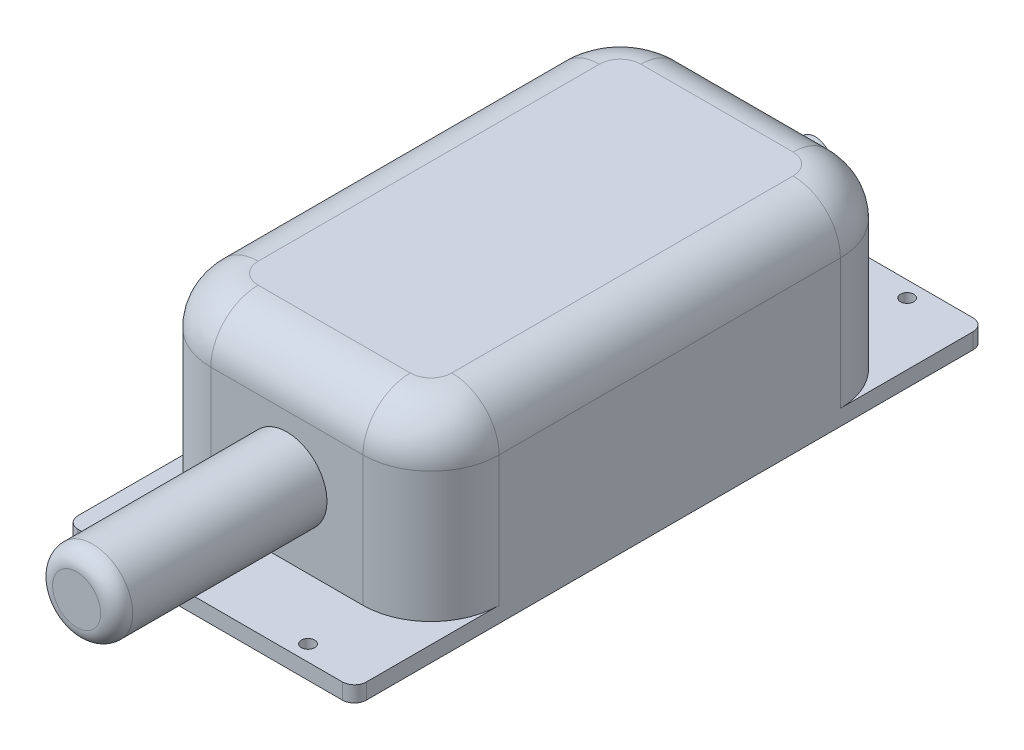
from build123d import *

# Parameters (mm, degrees)
SKETCH1_W           = 91.4146
SKETCH1_H           = 199.9996
BOSS_EXTRUDE1_DEPTH = 5.0038
BOSS_EXTRUDE2_DEPTH = 56.3118
FILLET1_R           = 15.0114
CUT_EXTRUDE1_REACH  = 7.004
SKETCH3_R           = 2.1082
FILLET2_R           = 3.81
SKETCH5_R           = 12.7
BOSS_EXTRUDE3_DEPTH = 66.675
FILLET3_R           = 5.08
SKETCH6_R           = 5.588
BOSS_EXTRUDE4_DEPTH = 16.1544


with BuildPart() as part:
    # Sketch1 → Boss-Extrude1 (new body)
    with BuildSketch(Plane(origin=(0, 0, 0), x_dir=(1, 0, 0), z_dir=(0, 1, 0))):
        Rectangle(SKETCH1_W, SKETCH1_H)
    extrude(amount=BOSS_EXTRUDE1_DEPTH)

    # Sketch2 → Boss-Extrude2 (add)
    with BuildSketch(Plane(origin=(0, 5.0038, 0), x_dir=(1, 0, 0), z_dir=(0, 1, 0))):
        with BuildLine():
            Line((-24.1173, 75.7047), (24.1173, 75.7047))
            ThreePointArc((24.1173, 75.7047), (39.383735406, 69.381135406), (45.7073, 54.1147))
            Line((45.7073, 54.1147), (45.7073, -54.1147))
            ThreePointArc((45.7073, -54.1147), (39.383735406, -69.381135406), (24.1173, -75.7047))
            Line((24.1173, -75.7047), (-24.1173, -75.7047))
            ThreePointArc((-24.1173, -75.7047), (-39.383735406, -69.381135406), (-45.7073, -54.1147))
            Line((-45.7073, -54.1147), (-45.7073, 54.1147))
            ThreePointArc((-45.7073, 54.1147), (-39.383735406, 69.381135406), (-24.1173, 75.7047))
        make_face()
    extrude(amount=BOSS_EXTRUDE2_DEPTH)

    # Fillet1
    fillet1_edges = [part.edges().sort_by_distance(p)[0] for p in [
        (-39.383735406, 61.3156, -69.381135406),
        (-45.7073, 61.3156, 0),
        (-39.383735406, 61.3156, 69.381135406),
        (0, 61.3156, 75.7047),
        (39.383735406, 61.3156, 69.381135406),
        (45.7073, 61.3156, 0),
        (39.383735406, 61.3156, -69.381135406),
        (0, 61.3156, -75.7047),
    ]]
    fillet(fillet1_edges, radius=FILLET1_R)

    # Sketch3 → Cut-Extrude1 (cut, up to next)
    with BuildSketch(Plane(origin=(0, 5.0038, 0), x_dir=(1, 0, 0), z_dir=(0, 1, 0)), mode=Mode.PRIVATE) as cut_extrude1_sk1:
        with Locations((25.9969, 94.996)):
            Circle(SKETCH3_R)
    cut_extrude1_tool1 = extrude(cut_extrude1_sk1.sketch, amount=-CUT_EXTRUDE1_REACH, mode=Mode.PRIVATE) & part.part
    add(cut_extrude1_tool1.solids().sort_by_distance((25.9969, 5.0038, -94.996))[0], mode=Mode.SUBTRACT)
    # Sketch3 → Cut-Extrude1 (cut, up to next)
    with BuildSketch(Plane(origin=(0, 5.0038, 0), x_dir=(1, 0, 0), z_dir=(0, 1, 0)), mode=Mode.PRIVATE) as cut_extrude1_sk2:
        with Locations((-25.9969, 94.996)):
            Circle(SKETCH3_R)
    cut_extrude1_tool2 = extrude(cut_extrude1_sk2.sketch, amount=-CUT_EXTRUDE1_REACH, mode=Mode.PRIVATE) & part.part
    add(cut_extrude1_tool2.solids().sort_by_distance((-25.9969, 5.0038, -94.996))[0], mode=Mode.SUBTRACT)
    # Sketch3 → Cut-Extrude1 (cut, up to next)
    with BuildSketch(Plane(origin=(0, 5.0038, 0), x_dir=(1, 0, 0), z_dir=(0, 1, 0)), mode=Mode.PRIVATE) as cut_extrude1_sk3:
        with Locations((25.9969, -94.996)):
            Circle(SKETCH3_R)
    cut_extrude1_tool3 = extrude(cut_extrude1_sk3.sketch, amount=-CUT_EXTRUDE1_REACH, mode=Mode.PRIVATE) & part.part
    add(cut_extrude1_tool3.solids().sort_by_distance((25.9969, 5.0038, 94.996))[0], mode=Mode.SUBTRACT)
    # Sketch3 → Cut-Extrude1 (cut, up to next)
    with BuildSketch(Plane(origin=(0, 5.0038, 0), x_dir=(1, 0, 0), z_dir=(0, 1, 0)), mode=Mode.PRIVATE) as cut_extrude1_sk4:
        with Locations((-25.9969, -94.996)):
            Circle(SKETCH3_R)
    cut_extrude1_tool4 = extrude(cut_extrude1_sk4.sketch, amount=-CUT_EXTRUDE1_REACH, mode=Mode.PRIVATE) & part.part
    add(cut_extrude1_tool4.solids().sort_by_distance((-25.9969, 5.0038, 94.996))[0], mode=Mode.SUBTRACT)

    # Fillet2
    fillet2_edges = [part.edges().sort_by_distance(p)[0] for p in [
        (45.7073, 2.5019, 99.9998),
        (-45.7073, 2.5019, 99.9998),
        (-45.7073, 2.5019, -99.9998),
        (45.7073, 2.5019, -99.9998),
    ]]
    fillet(fillet2_edges, radius=FILLET2_R)

    # Sketch5 → Boss-Extrude3 (add)
    with BuildSketch(Plane.XY.offset(75.7047)):
        with Locations((0, 27.8638)):
            Circle(SKETCH5_R)
    extrude(amount=BOSS_EXTRUDE3_DEPTH)

    # Fillet3
    fillet3_edges = [part.edges().sort_by_distance(p)[0] for p in [
        (-12.7, 27.8638, 142.3797),
    ]]
    fillet(fillet3_edges, radius=FILLET3_R)

    # Sketch6 → Boss-Extrude4 (add)
    with BuildSketch(Plane(origin=(0, 0, -75.7047), x_dir=(-1, 0, 0), z_dir=(0, 0, -1))):
        with Locations((0, 32.269838727)):
            Circle(SKETCH6_R)
    extrude(amount=BOSS_EXTRUDE4_DEPTH)


solid = part.part
